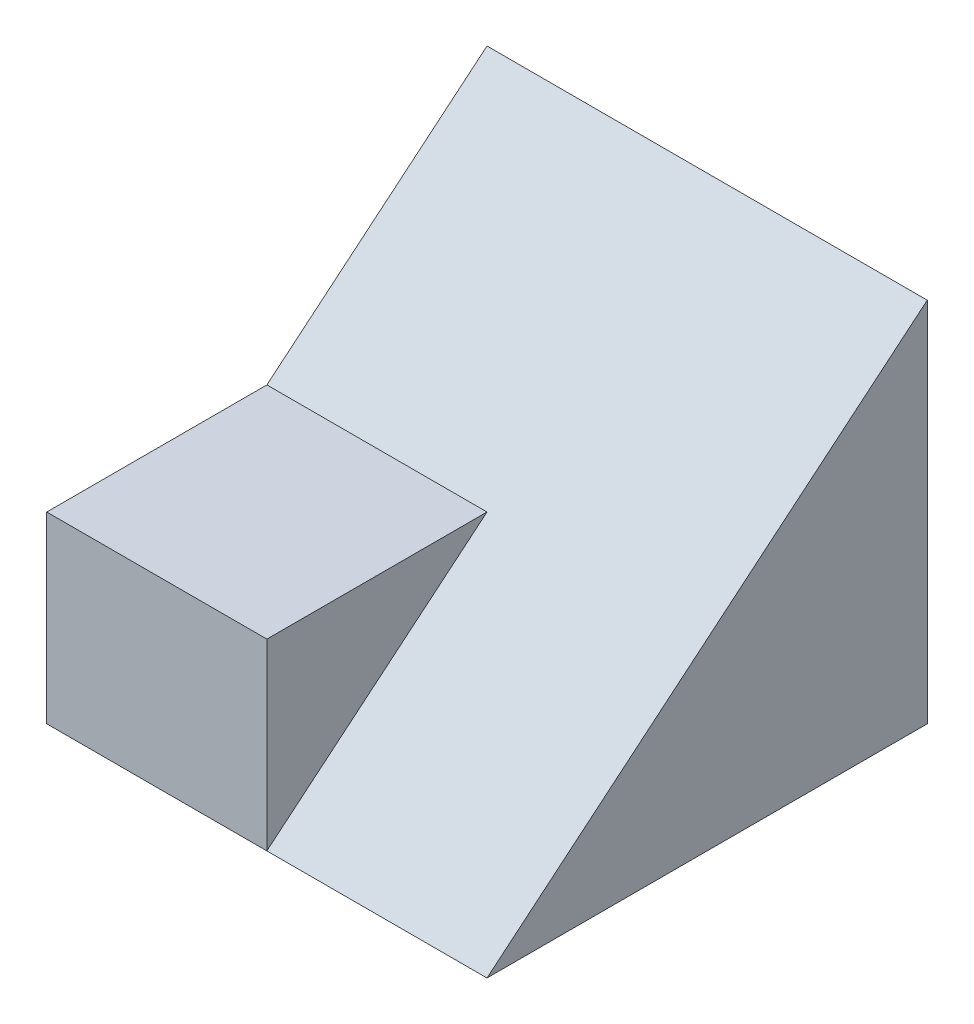
from build123d import *

# Parameters (mm, degrees)
SKETCH1_W           = 6
SKETCH1_H           = 6
BOSS_EXTRUDE1_DEPTH = 5
CUT_EXTRUDE1_DEPTH  = 10
CUT_EXTRUDE2_DEPTH  = 3


with BuildPart() as part:
    # Sketch1 → Boss-Extrude1 (new body)
    with BuildSketch(Plane(origin=(0, 0, 0), x_dir=(1, 0, 0), z_dir=(0, 1, 0))):
        Rectangle(SKETCH1_W, SKETCH1_H)
    extrude(amount=BOSS_EXTRUDE1_DEPTH)

    # Sketch2 → Cut-Extrude1 (cut)
    with BuildSketch(Plane.ZY.offset(3)):
        Polygon((3, 5), (-3, 5), (0, 2.5), (3, 2.5), align=None)
    extrude(amount=-CUT_EXTRUDE1_DEPTH, mode=Mode.SUBTRACT)

    # Sketch3 → Cut-Extrude2 (cut)
    with BuildSketch(Plane(origin=(3, 0, 0), x_dir=(0, 0, -1), z_dir=(1, 0, 0))):
        Polygon((-3, 0), (0, 2.5), (-3, 2.5), align=None)
    extrude(amount=-CUT_EXTRUDE2_DEPTH, mode=Mode.SUBTRACT)


solid = part.part
